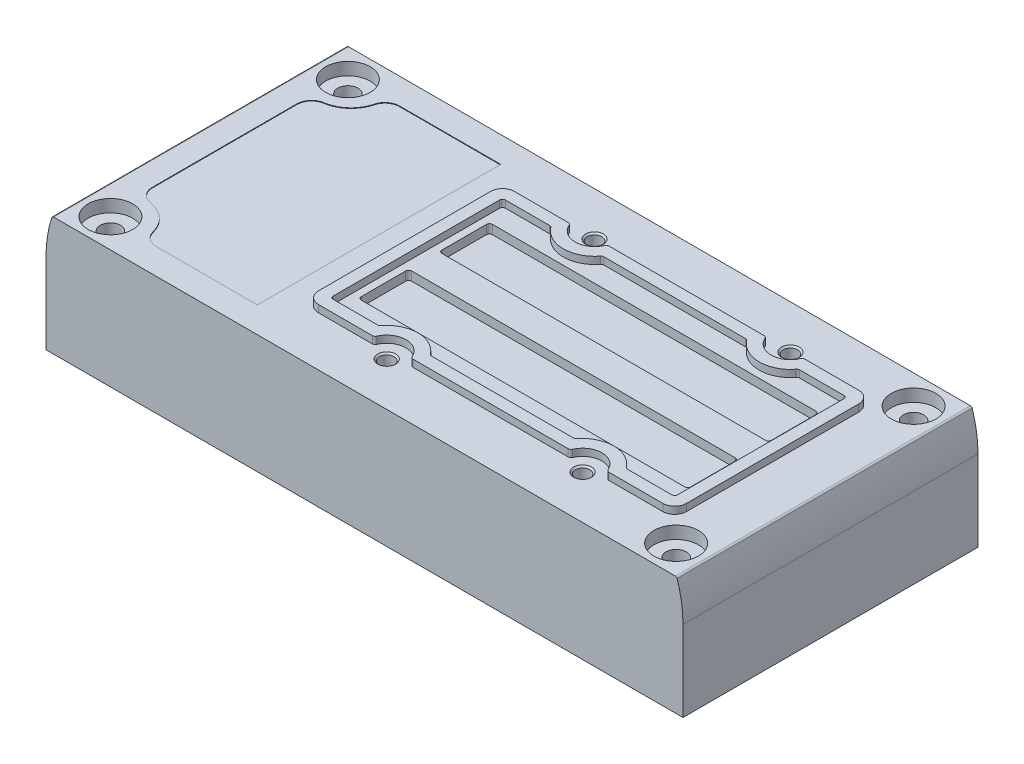
from build123d import *

# Parameters (mm, degrees)
BOSS_EXTRUDE1_DEPTH      = 24.85
BOSS_EXTRUDE1_DEPTH_BACK = 24.85
CUT_EXTRUDE1_DEPTH       = 1.5
CUT_EXTRUDE2_DEPTH       = 1.5
BOSS_EXTRUDE2_DEPTH      = 1.2
CUT_EXTRUDE3_DEPTH       = 0.1
CUT_EXTRUDE3_DEPTH_BACK  = 0.1
CUT_EXTRUDE4_DEPTH       = 19
CUT_EXTRUDE5_DEPTH       = 10


with BuildPart() as part:
    # Sketch1 → Boss-Extrude1 (new, two sides: drawn at the far end of the back side and taken through both)
    with BuildSketch(Plane.XY.offset(-BOSS_EXTRUDE1_DEPTH_BACK)):
        with BuildLine():
            Line((-53.65, 13.6), (-53.65, 0))
            Line((-53.65, 0), (53.65, 0))
            Line((53.65, 0), (53.65, 13.6))
            ThreePointArc((53.65, 13.6), (53.402733193, 16.735208348), (52.667046861, 19.792893401))
            ThreePointArc((52.667046861, 19.792893401), (52.558046626, 19.94276328), (52.381791158, 20))
            Line((52.381791158, 20), (-52.381791158, 20))
            ThreePointArc((-52.381791158, 20), (-52.558046626, 19.94276328), (-52.667046861, 19.792893401))
            ThreePointArc((-52.667046861, 19.792893401), (-53.402733193, 16.735208348), (-53.65, 13.6))
        make_face()
    extrude(amount=BOSS_EXTRUDE1_DEPTH + BOSS_EXTRUDE1_DEPTH_BACK)

    # Sketch2 → Cut-Revolve1 (revolve, cut)
    with BuildSketch(Plane.XY.offset(20)):
        Polygon((47.65, 20), (51.4, 20), (51.4, 17.9), (49.35, 17.9), (49.35, 12.773205081), (49.05, 12.6), (49.05, 12), (49.35, 12), (49.35, 0), (47.65, 0), align=None)
    revolve(axis=Axis((47.65, 0, 20), (0, 1, 0)), mode=Mode.SUBTRACT)

    # Sketch3 → Cut-Revolve2 (revolve, cut)
    with BuildSketch(Plane.XY.offset(-20)):
        Polygon((47.65, 20), (51.4, 20), (51.4, 17.9), (49.35, 17.9), (49.35, 12.773205081), (49.05, 12.6), (49.05, 12), (49.35, 12), (49.35, 0), (47.65, 0), align=None)
    revolve(axis=Axis((47.65, 0, -20), (0, 1, 0)), mode=Mode.SUBTRACT)

    # Sketch4 → Cut-Revolve3 (revolve, cut)
    with BuildSketch(Plane.XY.offset(-20)):
        Polygon((-47.65, 20), (-43.9, 20), (-43.9, 17.9), (-45.95, 17.9), (-45.95, 12.773205081), (-46.25, 12.6), (-46.25, 12), (-45.95, 12), (-45.95, 0), (-47.65, 0), align=None)
    revolve(axis=Axis((-47.65, 0, -20), (0, 1, 0)), mode=Mode.SUBTRACT)

    # Sketch5 → Cut-Revolve4 (revolve, cut)
    with BuildSketch(Plane.XY.offset(20)):
        Polygon((-47.65, 20), (-43.9, 20), (-43.9, 17.9), (-45.95, 17.9), (-45.95, 12.773205081), (-46.25, 12.6), (-46.25, 12), (-45.95, 12), (-45.95, 0), (-47.65, 0), align=None)
    revolve(axis=Axis((-47.65, 0, 20), (0, 1, 0)), mode=Mode.SUBTRACT)

    # Sketch6 → Cut-Extrude1 (cut)
    with BuildSketch(Plane(origin=(0, 20, 0), x_dir=(1, 0, 0), z_dir=(0, 1, 0))):
        with BuildLine():
            Line((-14.85, 10.52), (-14.85, 3.05))
            ThreePointArc((-14.85, 3.05), (-14.703553391, 2.696446609), (-14.35, 2.55))
            Line((-14.35, 2.55), (40.15, 2.55))
            ThreePointArc((40.15, 2.55), (40.503553391, 2.696446609), (40.65, 3.05))
            Line((40.65, 3.05), (40.65, 10.55))
            ThreePointArc((40.65, 10.55), (40.503553391, 10.903553391), (40.15, 11.05))
            Line((40.15, 11.05), (-14.32, 11.05))
            ThreePointArc((-14.32, 11.05), (-14.694766594, 10.894766594), (-14.85, 10.52))
        make_face()
    extrude(amount=-CUT_EXTRUDE1_DEPTH, mode=Mode.SUBTRACT)

    # Sketch7 → Cut-Extrude2 (cut)
    with BuildSketch(Plane(origin=(0, 20, 0), x_dir=(1, 0, 0), z_dir=(0, 1, 0))):
        with BuildLine():
            Line((-14.32, -11.05), (40.15, -11.05))
            ThreePointArc((40.15, -11.05), (40.503553391, -10.903553391), (40.65, -10.55))
            Line((40.65, -10.55), (40.65, -3.05))
            ThreePointArc((40.65, -3.05), (40.503553391, -2.696446609), (40.15, -2.55))
            Line((40.15, -2.55), (-14.35, -2.55))
            ThreePointArc((-14.35, -2.55), (-14.703553391, -2.696446609), (-14.85, -3.05))
            Line((-14.85, -3.05), (-14.85, -10.52))
            ThreePointArc((-14.85, -10.52), (-14.694766594, -10.894766594), (-14.32, -11.05))
        make_face()
    extrude(amount=-CUT_EXTRUDE2_DEPTH, mode=Mode.SUBTRACT)

    # Sketch8 → Boss-Extrude2 (add)
    with BuildSketch(Plane(origin=(0, 20, 0), x_dir=(1, 0, 0), z_dir=(0, 1, 0))):
        with BuildLine():
            Line((-18.1, 14.5), (-18.1, -14.5))
            ThreePointArc((-18.1, -14.5), (-17.514213562, -15.914213562), (-16.1, -16.5))
            Line((-16.1, -16.5), (-7.036931771, -16.5))
            ThreePointArc((-7.036931771, -16.5), (-6.763070492, -16.418330013), (-6.578674202, -16.2))
            ThreePointArc((-6.578674202, -16.2), (-3.6, -14.25), (-0.621325798, -16.2))
            ThreePointArc((-0.621325798, -16.2), (-0.436929508, -16.418330013), (-0.163068229, -16.5))
            Line((-0.163068229, -16.5), (25.963068229, -16.5))
            ThreePointArc((25.963068229, -16.5), (26.236929508, -16.418330013), (26.421325798, -16.2))
            ThreePointArc((26.421325798, -16.2), (29.4, -14.25), (32.378674202, -16.2))
            ThreePointArc((32.378674202, -16.2), (32.563070492, -16.418330013), (32.836931771, -16.5))
            Line((32.836931771, -16.5), (41.9, -16.5))
            ThreePointArc((41.9, -16.5), (43.314213562, -15.914213562), (43.9, -14.5))
            Line((43.9, -14.5), (43.9, 14.5))
            ThreePointArc((43.9, 14.5), (43.314213562, 15.914213562), (41.9, 16.5))
            Line((41.9, 16.5), (32.836931771, 16.5))
            ThreePointArc((32.836931771, 16.5), (32.563070514, 16.418330027), (32.378674222, 16.200000047))
            ThreePointArc((32.378674222, 16.200000047), (29.400000026, 14.25), (26.421325798, 16.2))
            ThreePointArc((26.421325798, 16.2), (26.236929508, 16.418330013), (25.963068229, 16.5))
            Line((25.963068229, 16.5), (-0.163068229, 16.5))
            ThreePointArc((-0.163068229, 16.5), (-0.436929508, 16.418330013), (-0.621325798, 16.2))
            ThreePointArc((-0.621325798, 16.2), (-3.6, 14.25), (-6.578674202, 16.2))
            ThreePointArc((-6.578674202, 16.2), (-6.763070492, 16.418330013), (-7.036931771, 16.5))
            Line((-7.036931771, 16.5), (-16.1, 16.5))
            ThreePointArc((-16.1, 16.5), (-17.514213562, 15.914213562), (-18.1, 14.5))
        make_face()
        with BuildLine():
            Line((-16.1, 14), (-16.1, -14))
            ThreePointArc((-16.1, -14), (-15.953553391, -14.353553391), (-15.6, -14.5))
            Line((-15.6, -14.5), (-8.162071898, -14.5))
            ThreePointArc((-8.162071898, -14.5), (-7.940908996, -14.448427219), (-7.765370037, -14.304347883))
            ThreePointArc((-7.765370037, -14.304347883), (-3.600000036, -12.25), (0.565369994, -14.304347826))
            ThreePointArc((0.565369994, -14.304347826), (0.740908963, -14.448427203), (0.962071898, -14.5))
            Line((0.962071898, -14.5), (24.837928102, -14.5))
            ThreePointArc((24.837928102, -14.5), (25.059091037, -14.448427203), (25.234630006, -14.304347826))
            ThreePointArc((25.234630006, -14.304347826), (29.400000067, -12.25), (33.565370075, -14.304347932))
            ThreePointArc((33.565370075, -14.304347932), (33.740909023, -14.448427233), (33.962071898, -14.5))
            Line((33.962071898, -14.5), (41.4, -14.5))
            ThreePointArc((41.4, -14.5), (41.753553391, -14.353553391), (41.9, -14))
            Line((41.9, -14), (41.9, 14))
            ThreePointArc((41.9, 14), (41.753553391, 14.353553391), (41.4, 14.5))
            Line((41.4, 14.5), (33.962071898, 14.5))
            ThreePointArc((33.962071898, 14.5), (33.740908985, 14.448427214), (33.565370022, 14.304347863))
            ThreePointArc((33.565370022, 14.304347863), (29.400000024, 12.25), (25.234630006, 14.304347826))
            ThreePointArc((25.234630006, 14.304347826), (25.059091037, 14.448427203), (24.837928102, 14.5))
            Line((24.837928102, 14.5), (0.962071898, 14.5))
            ThreePointArc((0.962071898, 14.5), (0.740908963, 14.448427203), (0.565369994, 14.304347826))
            ThreePointArc((0.565369994, 14.304347826), (-3.6, 12.25), (-7.765369994, 14.304347826))
            ThreePointArc((-7.765369994, 14.304347826), (-7.940908963, 14.448427203), (-8.162071898, 14.5))
            Line((-8.162071898, 14.5), (-15.6, 14.5))
            ThreePointArc((-15.6, 14.5), (-15.953553391, 14.353553391), (-16.1, 14))
        make_face(mode=Mode.SUBTRACT)
    extrude(amount=BOSS_EXTRUDE2_DEPTH)

    # Sketch9 → Cut-Extrude3 (cut, two sides: drawn at the far end of the back side and taken through both)
    with BuildSketch(Plane(origin=(0, 20, 0), x_dir=(1, 0, 0), z_dir=(0, 1, 0)).offset(-CUT_EXTRUDE3_DEPTH_BACK)):
        with BuildLine():
            Line((-48.4, 12.151203914), (-48.4, -12.151203914))
            ThreePointArc((-48.4, -12.151203914), (-47.79906628, -13.773402604), (-46.286322418, -14.612602183))
            ThreePointArc((-46.286322418, -14.612602183), (-43.456956945, -15.955525197), (-41.833947517, -18.63406801))
            ThreePointArc((-41.833947517, -18.63406801), (-40.94758788, -19.979013629), (-39.423420787, -20.5))
            Line((-39.423420787, -20.5), (-22.4, -20.5))
            Line((-22.4, -20.5), (-22.4, 20.5))
            Line((-22.4, 20.5), (-39.423420787, 20.5))
            ThreePointArc((-39.423420787, 20.5), (-40.94758788, 19.979013629), (-41.833947517, 18.63406801))
            ThreePointArc((-41.833947517, 18.63406801), (-43.456956895, 15.955525241), (-46.286322286, 14.612602203))
            ThreePointArc((-46.286322286, 14.612602203), (-47.799066237, 13.773402654), (-48.4, 12.151203914))
        make_face()
    extrude(amount=CUT_EXTRUDE3_DEPTH + CUT_EXTRUDE3_DEPTH_BACK, mode=Mode.SUBTRACT)

    # Sketch10 → Cut-Extrude4 (cut)
    with BuildSketch(Plane(origin=(0, 0, 0), x_dir=(1, 0, 0), z_dir=(0, 1, 0))):
        with BuildLine():
            Line((-48.4, 12.151203914), (-48.4, -12.151203914))
            ThreePointArc((-48.4, -12.151203914), (-47.79906628, -13.773402604), (-46.286322418, -14.612602183))
            ThreePointArc((-46.286322418, -14.612602183), (-43.456956945, -15.955525197), (-41.833947517, -18.63406801))
            ThreePointArc((-41.833947517, -18.63406801), (-40.94758788, -19.979013629), (-39.423420787, -20.5))
            Line((-39.423420787, -20.5), (-22.4, -20.5))
            Line((-22.4, -20.5), (-22.4, 20.5))
            Line((-22.4, 20.5), (-39.423420787, 20.5))
            ThreePointArc((-39.423420787, 20.5), (-40.94758788, 19.979013629), (-41.833947517, 18.63406801))
            ThreePointArc((-41.833947517, 18.63406801), (-43.456956895, 15.955525241), (-46.286322286, 14.612602203))
            ThreePointArc((-46.286322286, 14.612602203), (-47.799066237, 13.773402654), (-48.4, 12.151203914))
        make_face()
    extrude(amount=CUT_EXTRUDE4_DEPTH, mode=Mode.SUBTRACT)

    # Sketch11 → Cut-Extrude5 (cut)
    with BuildSketch(Plane(origin=(0, 0, 0), x_dir=(1, 0, 0), z_dir=(0, 1, 0))):
        with BuildLine():
            Line((-22.4, -20.5), (40.207977783, -20.5))
            ThreePointArc((40.207977783, -20.5), (41.419271502, -20.057764768), (42.060696328, -18.939114391))
            ThreePointArc((42.060696328, -18.939114391), (43.712891101, -15.670049726), (46.913111931, -13.888163649))
            ThreePointArc((46.913111931, -13.888163649), (47.981754157, -13.231956241), (48.4, -12.049723275))
            Line((48.4, -12.049723275), (48.4, 12.049723275))
            ThreePointArc((48.4, 12.049723275), (47.981754157, 13.231956241), (46.913111931, 13.888163649))
            ThreePointArc((46.913111931, 13.888163649), (43.712891101, 15.670049726), (42.060696328, 18.939114391))
            ThreePointArc((42.060696328, 18.939114391), (41.419271502, 20.057764768), (40.207977783, 20.5))
            Line((40.207977783, 20.5), (-22.4, 20.5))
            Line((-22.4, 20.5), (-22.4, -20.5))
        make_face()
    extrude(amount=CUT_EXTRUDE5_DEPTH, mode=Mode.SUBTRACT)

    # Sketch12 → Cut-Revolve5 (revolve, cut)
    with BuildSketch(Plane.XY.offset(-17.5)):
        Polygon((-3.6, 20), (-2.1, 20), (-2.3705, 19.7295), (-2.3705, 13.4), (-3.6, 13.4), align=None)
    revolve(axis=Axis((-3.6, 13.4, -17.5), (0, 1, 0)), mode=Mode.SUBTRACT)

    # Sketch13 → Cut-Revolve6 (revolve, cut)
    with BuildSketch(Plane.XY.offset(17.5)):
        Polygon((-3.6, 20), (-2.1, 20), (-2.3705, 19.7295), (-2.3705, 13.4), (-3.6, 13.4), align=None)
    revolve(axis=Axis((-3.6, 13.4, 17.5), (0, 1, 0)), mode=Mode.SUBTRACT)

    # Sketch14 → Cut-Revolve7 (revolve, cut)
    with BuildSketch(Plane.XY.offset(17.5)):
        Polygon((29.4, 20), (30.9, 20), (30.6295, 19.7295), (30.6295, 13.4), (29.4, 13.4), align=None)
    revolve(axis=Axis((29.4, 13.4, 17.5), (0, 1, 0)), mode=Mode.SUBTRACT)

    # Sketch15 → Cut-Revolve8 (revolve, cut)
    with BuildSketch(Plane.XY.offset(-17.5)):
        Polygon((29.4, 20), (30.9, 20), (30.6295, 19.7295), (30.6295, 13.4), (29.4, 13.4), align=None)
    revolve(axis=Axis((29.4, 13.4, -17.5), (0, 1, 0)), mode=Mode.SUBTRACT)


solid = part.part
